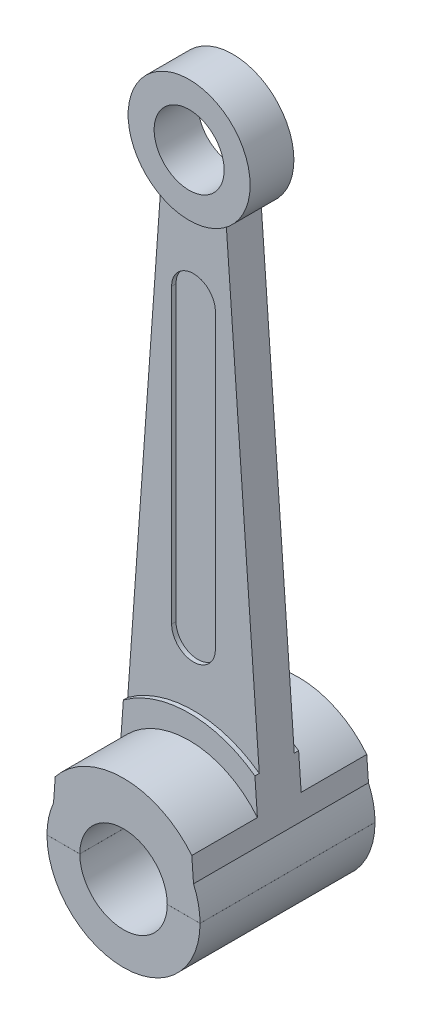
from build123d import *

# Parameters (mm, degrees)
SKETCH1_R                = 2.54
SKETCH1_R_2              = 1
BOSS_EXTRUDE1_DEPTH      = 0.5
SKETCH1_R_3              = 1.395
SKETCH1_R_4              = 0.8
BOSS_EXTRUDE1_2_DEPTH    = 0.5
BOSS_EXTRUDE2_DEPTH      = 0.4
BOSS_EXTRUDE3_DEPTH      = 0.3
BOSS_EXTRUDE4_DEPTH      = 1.5
BOSS_EXTRUDE4_DEPTH_BACK = 2.5
SKETCH2_R                = 2
SKETCH2_R_2              = 1
CUT_EXTRUDE1_DEPTH       = 20.75
CUT_EXTRUDE2_DEPTH       = 20.75


with BuildPart() as part:
    # Sketch1 → Boss-Extrude1 (new, symmetric)
    with BuildSketch(Plane.XY):
        Circle(SKETCH1_R)
        Circle(SKETCH1_R_2, mode=Mode.SUBTRACT)
    extrude(amount=BOSS_EXTRUDE1_DEPTH, both=True)



with BuildPart() as body_2:
    # Sketch1 → Boss-Extrude1 2 (new, symmetric)
    with BuildSketch(Plane.XY):
        with Locations((0, 13.69)):
            Circle(SKETCH1_R_3)
        with Locations((0, 13.69)):
            Circle(SKETCH1_R_4, mode=Mode.SUBTRACT)
    extrude(amount=BOSS_EXTRUDE1_2_DEPTH, both=True)


with BuildPart() as part_1:
    add(part.part)

    add(body_2.part)  # Boss-Extrude2 merges body 2
    # Sketch1_3 → Boss-Extrude2 (add, symmetric)
    with BuildSketch(Plane.XY):
        with BuildLine():
            Line((-0.75, 12.513766605), (-1.65, 1.931087776))
            ThreePointArc((-1.65, 1.931087776), (0, 2.54), (1.65, 1.931087776))
            Line((1.65, 1.931087776), (0.75, 12.513766605))
            ThreePointArc((0.75, 12.513766605), (0, 12.295), (-0.75, 12.513766605))
        make_face()
        with BuildLine():
            ThreePointArc((0.5, 4), (0, 3.5), (-0.5, 4))
            Line((-0.5, 4), (-0.5, 10.69))
            ThreePointArc((-0.5, 10.69), (0, 11.19), (0.5, 10.69))
            Line((0.5, 10.69), (0.5, 4))
        make_face(mode=Mode.SUBTRACT)
    extrude(amount=BOSS_EXTRUDE2_DEPTH, both=True)

    # Sketch1_4 → Boss-Extrude3 (add, symmetric)
    with BuildSketch(Plane.XY):
        with BuildLine():
            Line((-0.5, 4), (-0.5, 10.69))
            ThreePointArc((-0.5, 10.69), (0, 11.19), (0.5, 10.69))
            Line((0.5, 10.69), (0.5, 4))
            ThreePointArc((0.5, 4), (0, 3.5), (-0.5, 4))
        make_face()
    extrude(amount=BOSS_EXTRUDE3_DEPTH, both=True)

    # Sketch2 → Boss-Extrude4 (add, two sides: drawn at the far end of the back side and taken through both)
    with BuildSketch(Plane.XY.offset(0.5).offset(-BOSS_EXTRUDE4_DEPTH_BACK)):
        Circle(SKETCH2_R)
        Circle(SKETCH2_R_2, mode=Mode.SUBTRACT)
    extrude(amount=BOSS_EXTRUDE4_DEPTH + BOSS_EXTRUDE4_DEPTH_BACK)

    # Sketch3 → Cut-Extrude1 (cut, symmetric)
    with BuildSketch(Plane.XY):
        with BuildLine():
            Line((-0.75, 12.513766605), (-2.89360139, 1.969027932))
            ThreePointArc((-2.89360139, 1.969027932), (0, -3.5), (2.89360139, 1.969027932))
            Line((2.89360139, 1.969027932), (0.75, 12.513766605))
            Line((0.75, 12.513766605), (1.6, 0.708872344))
            ThreePointArc((1.6, 0.708872344), (0, -1.75), (-1.6, 0.708872344))
            Line((-1.6, 0.708872344), (-0.75, 12.513766605))
        make_face()
    extrude(amount=CUT_EXTRUDE1_DEPTH, both=True, mode=Mode.SUBTRACT)

    # Sketch4 → Cut-Extrude2 (cut, symmetric)
    with BuildSketch(Plane.XY):
        Polygon((2.586715497, 0), (-2.840346432, 0), (2.586715497, 0.001), align=None)
    extrude(amount=CUT_EXTRUDE2_DEPTH, both=True, mode=Mode.SUBTRACT)


with BuildPart() as cut_extrude2_piece_1:
    # of the separate pieces the step leaves, piece 1, a body of its own (cut_extrude2_pieces)
    add(part_1.part.solids().sort_by_distance((1.395, 13.69, -0.5))[0])


with BuildPart() as cut_extrude2_piece_2:
    # of the separate pieces the step leaves, piece 2, a body of its own (cut_extrude2_pieces)
    add(part_1.part.solids().sort_by_distance((-1.75, 0, -2))[0])


solid = Compound([cut_extrude2_piece_1.part, cut_extrude2_piece_2.part])
